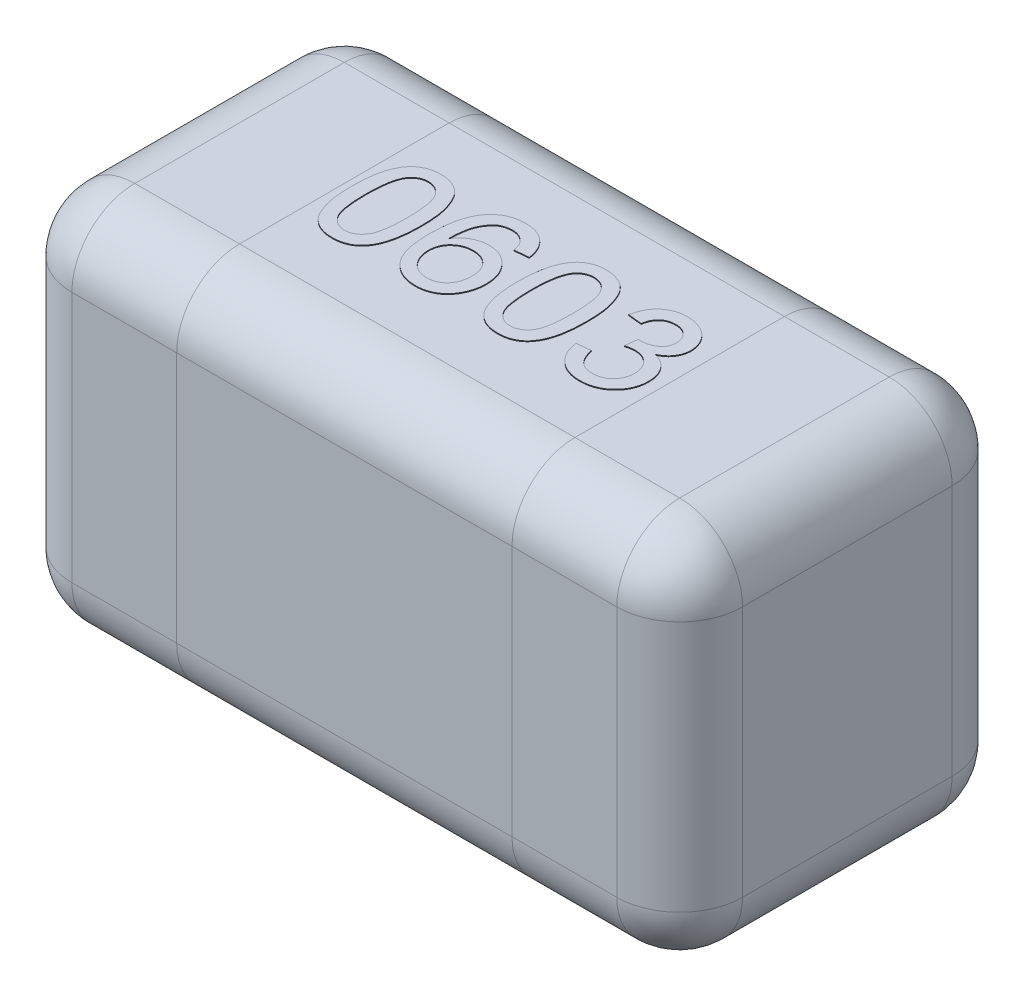
from build123d import *

# Parameters (mm, degrees)
SKETCH1_W      = 1.6
SKETCH1_H      = 0.8
EXTRUDE1_DEPTH = 0.9
FILLET1_R      = 0.15
EXTRUDE2_DEPTH = 0.002


with BuildPart() as part:
    # Sketch1 → Extrude1 (new body)
    with BuildSketch(Plane(origin=(0, 0, 0), x_dir=(1, 0, 0), z_dir=(0, 1, 0))):
        Rectangle(SKETCH1_W, SKETCH1_H)
    extrude(amount=EXTRUDE1_DEPTH)

    # Fillet1
    fillet1_edges = [part.edges().sort_by_distance(p)[0] for p in [
        (0.8, 0.9, 0),
        (0, 0.9, -0.4),
        (-0.8, 0.9, 0),
        (0, 0, -0.4),
        (0.8, 0, 0),
        (0, 0, 0.4),
        (-0.8, 0, 0),
        (0, 0.9, 0.4),
        (-0.8, 0.45, -0.4),
        (0.8, 0.45, -0.4),
        (0.8, 0.45, 0.4),
        (-0.8, 0.45, 0.4),
    ]]
    fillet(fillet1_edges, radius=FILLET1_R)

    # Sketch3 → Extrude2 (add)
    with BuildSketch(Plane(origin=(0, 0.9, 0), x_dir=(1, 0, 0), z_dir=(0, 1, 0))):
        with BuildLine():
            add(Edge.make_bspline(
                [(-0.383536419, 0.001666679), (-0.383503245, 0.005337042), (-0.38343827, 0.012525738), (-0.383035257, 0.023044091), (-0.382331628, 0.033032936), (-0.381281304, 0.042483597), (-0.380037523, 0.051417406), (-0.378420601, 0.059821615), (-0.376601328, 0.067715078), (-0.374418526, 0.07508957), (-0.372020342, 0.082008496), (-0.369299526, 0.088460757), (-0.366238239, 0.094439512), (-0.362986924, 0.100006765), (-0.359374425, 0.105075921), (-0.355618786, 0.109789243), (-0.351447068, 0.113973873), (-0.347032741, 0.117737484), (-0.342310804, 0.12105865), (-0.337306239, 0.123924417), (-0.332038302, 0.126454682), (-0.326406594, 0.128359465), (-0.320528026, 0.129912267), (-0.314357349, 0.131054526), (-0.307887763, 0.131727927), (-0.30346671, 0.13179683), (-0.301218512, 0.131831868)],
                knots=[0, 0, 0, 0, 1.1011e-05, 2.1566e-05, 3.1573e-05, 4.1044e-05, 5.0088e-05, 5.8625e-05, 6.6711e-05, 7.4379e-05, 8.1685e-05, 8.867e-05, 9.5366e-05, 0.000101825, 0.000107991, 0.000114026, 0.000119883, 0.000125687, 0.00013141, 0.000137173, 0.000142973, 0.000148912, 0.000154976, 0.000161203, 0.00016772, 0.000174462, 0.000174462, 0.000174462, 0.000174462], degree=3))
            add(Edge.make_bspline(
                [(-0.301218512, 0.131831868), (-0.297920113, 0.131734898), (-0.291440277, 0.131544395), (-0.281979682, 0.129990691), (-0.273063682, 0.127332839), (-0.264698068, 0.123747283), (-0.257025849, 0.119192937), (-0.250174234, 0.113656435), (-0.24421713, 0.10719591), (-0.239219547, 0.099734806), (-0.234851161, 0.091478951), (-0.230970383, 0.08239129), (-0.227462272, 0.072482005), (-0.22497284, 0.063611812), (-0.223197131, 0.055954747), (-0.222021752, 0.049639416), (-0.221045952, 0.042825138), (-0.220298357, 0.035528399), (-0.219684974, 0.027757383), (-0.219211285, 0.019507252), (-0.21897084, 0.010757385), (-0.218924456, 0.004753721), (-0.218900606, 0.001666679)],
                knots=[0, 0, 0, 0, 9.892e-06, 1.9432e-05, 2.8662e-05, 3.7742e-05, 4.6671e-05, 5.5341e-05, 6.408e-05, 7.2927e-05, 8.2203e-05, 9.2066e-05, 0.000102546, 0.000113719, 0.000119684, 0.000126122, 0.000132983, 0.00014033, 0.000148123, 0.000156368, 0.000165118, 0.000174379, 0.000174379, 0.000174379, 0.000174379], degree=3))
            add(Edge.make_bspline(
                [(-0.218900606, 0.001666679), (-0.218934401, -0.001986444), (-0.219000427, -0.009123539), (-0.219392642, -0.019557553), (-0.220138669, -0.029471036), (-0.22105667, -0.038886699), (-0.222445412, -0.047779404), (-0.223941857, -0.056186936), (-0.22579259, -0.064071116), (-0.227951961, -0.071435401), (-0.230383903, -0.078318728), (-0.233050903, -0.08477312), (-0.236004862, -0.090794165), (-0.239333701, -0.096323138), (-0.24288511, -0.101433426), (-0.2466851, -0.106144199), (-0.250814234, -0.110387655), (-0.255268341, -0.114139976), (-0.259957124, -0.117520039), (-0.264973856, -0.120414099), (-0.27029658, -0.122811778), (-0.27588973, -0.124861674), (-0.28181006, -0.126363718), (-0.28801088, -0.127513508), (-0.294515039, -0.128190589), (-0.298953192, -0.128258204), (-0.301218512, -0.128292716)],
                knots=[0, 0, 0, 0, 1.096e-05, 2.1412e-05, 3.1316e-05, 4.0782e-05, 4.9783e-05, 5.831e-05, 6.6396e-05, 7.4064e-05, 8.1321e-05, 8.8287e-05, 9.5005e-05, 0.00010142, 0.000107628, 0.000113663, 0.000119557, 0.00012536, 0.000131114, 0.000136876, 0.000142701, 0.000148609, 0.000154724, 0.000161, 0.000167517, 0.000174312, 0.000174312, 0.000174312, 0.000174312], degree=3))
            add(Edge.make_bspline(
                [(-0.301218512, -0.128292716), (-0.30418861, -0.128207994), (-0.309979483, -0.128042809), (-0.318436626, -0.126920479), (-0.326374106, -0.124945125), (-0.333858871, -0.122295898), (-0.34080679, -0.118752403), (-0.347251037, -0.11444105), (-0.353321103, -0.109462146), (-0.356815403, -0.105533906), (-0.358583803, -0.103545896)],
                knots=[0, 0, 0, 0, 8.91e-06, 1.7372e-05, 2.5533e-05, 3.341e-05, 4.1141e-05, 4.8861e-05, 5.664e-05, 6.4612e-05, 6.4612e-05, 6.4612e-05, 6.4612e-05], degree=3))
            add(Edge.make_bspline(
                [(-0.358583803, -0.103545896), (-0.360619273, -0.100609701), (-0.364816498, -0.094555141), (-0.369728987, -0.084231556), (-0.374111014, -0.072866738), (-0.377550101, -0.060237711), (-0.380243764, -0.046444988), (-0.382189261, -0.031461504), (-0.383290221, -0.015293733), (-0.3834525, -0.004114416), (-0.383536419, 0.001666679)],
                knots=[0, 0, 0, 0, 1.0702e-05, 2.2069e-05, 3.4184e-05, 4.7216e-05, 6.1271e-05, 7.6319e-05, 9.2514e-05, 0.000109857, 0.000109857, 0.000109857, 0.000109857], degree=3))
        make_face()
        with BuildLine():
            add(Edge.make_bspline(
                [(-0.350609256, 0.001769576), (-0.350576562, -0.003170235), (-0.350513978, -0.012626126), (-0.349860131, -0.026135497), (-0.34873456, -0.038322794), (-0.347246481, -0.049171143), (-0.345281615, -0.058695218), (-0.342814493, -0.066870748), (-0.34003346, -0.07379586), (-0.336591985, -0.07938472), (-0.332823949, -0.083940457), (-0.328933709, -0.087858537), (-0.324829742, -0.091188816), (-0.320538825, -0.09396559), (-0.315994382, -0.09606798), (-0.311246106, -0.097591797), (-0.306292962, -0.098468731), (-0.302919647, -0.09859473), (-0.301218512, -0.09865827)],
                knots=[0, 0, 0, 0, 1.4819e-05, 2.8366e-05, 4.0561e-05, 5.1526e-05, 6.1202e-05, 6.9698e-05, 7.7123e-05, 8.352e-05, 8.9297e-05, 9.4827e-05, 0.000100058, 0.000105124, 0.000110119, 0.000115033, 0.000120049, 0.000125152, 0.000125152, 0.000125152, 0.000125152], degree=3))
            add(Edge.make_bspline(
                [(-0.301218512, -0.09865827), (-0.299517804, -0.098593341), (-0.296145333, -0.098464589), (-0.291180745, -0.097606993), (-0.286450942, -0.096004731), (-0.281913275, -0.093909766), (-0.277591171, -0.091196284), (-0.273507359, -0.087853425), (-0.269596627, -0.083937671), (-0.265845517, -0.079328982), (-0.26243026, -0.073714283), (-0.259597059, -0.066794813), (-0.257168385, -0.058604965), (-0.255192738, -0.049085742), (-0.253698521, -0.038254546), (-0.252579755, -0.026101051), (-0.251921532, -0.012609061), (-0.251859981, -0.003170257), (-0.251827768, 0.001769576)],
                knots=[0, 0, 0, 0, 5.103e-06, 1.0119e-05, 1.5048e-05, 2.0043e-05, 2.5082e-05, 3.0313e-05, 3.5843e-05, 4.166e-05, 4.8101e-05, 5.5478e-05, 6.4023e-05, 7.37e-05, 8.4614e-05, 9.6809e-05, 0.000110305, 0.000125123, 0.000125123, 0.000125123, 0.000125123], degree=3))
            add(Edge.make_bspline(
                [(-0.251827768, 0.001769576), (-0.25185895, 0.006606627), (-0.251918692, 0.015874235), (-0.252593892, 0.029123348), (-0.25365199, 0.041106086), (-0.2550993, 0.051833497), (-0.257022775, 0.061293933), (-0.259355688, 0.069507536), (-0.262135702, 0.076456788), (-0.265441129, 0.082211494), (-0.269120731, 0.086931915), (-0.272964424, 0.09101785), (-0.277068301, 0.094492804), (-0.28150507, 0.097280464), (-0.286131725, 0.099529444), (-0.291054577, 0.101077249), (-0.296225236, 0.102028172), (-0.299773792, 0.102140361), (-0.301578653, 0.102197422)],
                knots=[0, 0, 0, 0, 1.451e-05, 2.7801e-05, 3.9785e-05, 5.059e-05, 6.0257e-05, 6.8723e-05, 7.6175e-05, 8.2653e-05, 8.8559e-05, 9.4091e-05, 9.946e-05, 0.000104641, 0.000109772, 0.000114849, 0.000120076, 0.000125487, 0.000125487, 0.000125487, 0.000125487], degree=3))
            add(Edge.make_bspline(
                [(-0.301578653, 0.102197422), (-0.303279681, 0.102152777), (-0.306633889, 0.102064742), (-0.311544889, 0.101224452), (-0.316198987, 0.099819298), (-0.320649502, 0.097915882), (-0.324785331, 0.095354259), (-0.328770489, 0.092363383), (-0.332418328, 0.088719333), (-0.334616483, 0.085995099), (-0.335740584, 0.08460197)],
                knots=[0, 0, 0, 0, 5.1e-06, 1.0056e-05, 1.4891e-05, 1.966e-05, 2.4531e-05, 2.9449e-05, 3.4579e-05, 3.9948e-05, 3.9948e-05, 3.9948e-05, 3.9948e-05], degree=3))
            add(Edge.make_bspline(
                [(-0.335740584, 0.08460197), (-0.336964387, 0.082555894), (-0.339548802, 0.078235014), (-0.342440611, 0.070725147), (-0.344995121, 0.062142798), (-0.34709833, 0.052355922), (-0.348619854, 0.041381307), (-0.349821038, 0.029231698), (-0.350445009, 0.015890133), (-0.350552996, 0.006606292), (-0.350609256, 0.001769576)],
                knots=[0, 0, 0, 0, 7.141e-06, 1.508e-05, 2.4049e-05, 3.3999e-05, 4.5073e-05, 5.7272e-05, 7.0614e-05, 8.5125e-05, 8.5125e-05, 8.5125e-05, 8.5125e-05], degree=3))
        make_face(mode=Mode.SUBTRACT)
        with BuildLine():
            Line((-0.024630346, 0.065977543), (-0.057557509, 0.062684827))
            add(Edge.make_bspline(
                [(-0.057557509, 0.062684827), (-0.05826805, 0.065516739), (-0.059605536, 0.070847376), (-0.06241023, 0.078077583), (-0.065500943, 0.084193107), (-0.068186101, 0.087486148), (-0.069442156, 0.089026557)],
                knots=[0, 0, 0, 0, 8.749e-06, 1.647e-05, 2.3237e-05, 2.9184e-05, 2.9184e-05, 2.9184e-05, 2.9184e-05], degree=3))
            add(Edge.make_bspline(
                [(-0.069442156, 0.089026557), (-0.070520334, 0.0900772), (-0.072640859, 0.092143573), (-0.076121989, 0.094837104), (-0.079791677, 0.097119199), (-0.083661013, 0.098968041), (-0.087709093, 0.100428521), (-0.091952687, 0.101450204), (-0.096382179, 0.102082684), (-0.099400325, 0.10215885), (-0.100928756, 0.102197422)],
                knots=[0, 0, 0, 0, 4.513e-06, 8.877e-06, 1.3174e-05, 1.7454e-05, 2.1718e-05, 2.6061e-05, 3.0528e-05, 3.5112e-05, 3.5112e-05, 3.5112e-05, 3.5112e-05], degree=3))
            add(Edge.make_bspline(
                [(-0.100928756, 0.102197422), (-0.103406605, 0.102117638), (-0.108302727, 0.101959989), (-0.115486212, 0.100416617), (-0.122463396, 0.098106714), (-0.126786019, 0.095765152), (-0.128968293, 0.094583016)],
                knots=[0, 0, 0, 0, 7.423e-06, 1.4668e-05, 2.1957e-05, 2.9388e-05, 2.9388e-05, 2.9388e-05, 2.9388e-05], degree=3))
            add(Edge.make_bspline(
                [(-0.128968293, 0.094583016), (-0.131114423, 0.092804891), (-0.135519915, 0.089154828), (-0.141269136, 0.082410274), (-0.146410589, 0.0745576), (-0.150202503, 0.06722653), (-0.152871131, 0.060653582), (-0.154597055, 0.055020365), (-0.156071643, 0.048796819), (-0.157300057, 0.041994671), (-0.158250156, 0.034608403), (-0.159044249, 0.026633324), (-0.15948345, 0.018049212), (-0.159581272, 0.012128344), (-0.159631713, 0.00907529)],
                knots=[0, 0, 0, 0, 8.349e-06, 1.7138e-05, 2.6456e-05, 3.6465e-05, 4.1844e-05, 4.7719e-05, 5.412e-05, 6.1023e-05, 6.8445e-05, 7.6456e-05, 8.5061e-05, 9.4221e-05, 9.4221e-05, 9.4221e-05, 9.4221e-05], degree=3))
            add(Edge.make_bspline(
                [(-0.159631713, 0.00907529), (-0.157690438, 0.011802723), (-0.153890275, 0.017141839), (-0.147186499, 0.024125799), (-0.139866285, 0.030029462), (-0.13192145, 0.034743141), (-0.123559298, 0.038396359), (-0.114964225, 0.041025178), (-0.106151296, 0.042638817), (-0.100215195, 0.042831467), (-0.09722445, 0.042928529)],
                knots=[0, 0, 0, 0, 1.0032e-05, 1.9639e-05, 2.8936e-05, 3.8165e-05, 4.7265e-05, 5.6249e-05, 6.5079e-05, 7.4046e-05, 7.4046e-05, 7.4046e-05, 7.4046e-05], degree=3))
            add(Edge.make_bspline(
                [(-0.09722445, 0.042928529), (-0.094648686, 0.042859228), (-0.089559774, 0.04272231), (-0.082065775, 0.041637295), (-0.074881238, 0.03973953), (-0.067943904, 0.037267256), (-0.061387084, 0.03389162), (-0.055050754, 0.029946495), (-0.049081666, 0.025145731), (-0.043404274, 0.019751525), (-0.038235229, 0.013754368), (-0.033660257, 0.007299719), (-0.02984777, 0.000372108), (-0.026756285, -0.006982072), (-0.024336657, -0.014736058), (-0.022578509, -0.022911872), (-0.021549314, -0.031525671), (-0.021409136, -0.037414409), (-0.02133763, -0.040418351)],
                knots=[0, 0, 0, 0, 7.726e-06, 1.5264e-05, 2.2651e-05, 2.9992e-05, 3.7308e-05, 4.4731e-05, 5.2348e-05, 6.0244e-05, 6.8196e-05, 7.6061e-05, 8.3937e-05, 9.1868e-05, 9.9955e-05, 0.00010827, 0.000116924, 0.000125934, 0.000125934, 0.000125934, 0.000125934], degree=3))
            add(Edge.make_bspline(
                [(-0.02133763, -0.040418351), (-0.021465744, -0.044388292), (-0.021718575, -0.052222876), (-0.02374794, -0.063760347), (-0.02701796, -0.074881354), (-0.030929731, -0.083688228), (-0.034523627, -0.090435234), (-0.037575266, -0.09515439), (-0.040838328, -0.099589207), (-0.044251006, -0.103800713), (-0.048060824, -0.107596153), (-0.052036809, -0.111154368), (-0.056310381, -0.114352339), (-0.060755852, -0.117296475), (-0.065457198, -0.11984934), (-0.070277623, -0.122117837), (-0.075256809, -0.124050179), (-0.080410832, -0.125567394), (-0.085713296, -0.126822617), (-0.091181851, -0.127685698), (-0.096802104, -0.128217982), (-0.100601712, -0.128267612), (-0.102523665, -0.128292716)],
                knots=[0, 0, 0, 0, 1.1903e-05, 2.3491e-05, 3.5032e-05, 4.6598e-05, 5.233e-05, 5.7953e-05, 6.3438e-05, 6.8846e-05, 7.4194e-05, 7.9552e-05, 8.4841e-05, 9.0192e-05, 9.5534e-05, 0.000100874, 0.000106167, 0.000111538, 0.00011698, 0.000122503, 0.000128134, 0.000133899, 0.000133899, 0.000133899, 0.000133899], degree=3))
            add(Edge.make_bspline(
                [(-0.102523665, -0.128292716), (-0.105769485, -0.128202708), (-0.112135109, -0.128026186), (-0.12145213, -0.126670063), (-0.13029905, -0.124403791), (-0.138694686, -0.121235286), (-0.146664615, -0.117235114), (-0.154130294, -0.112220622), (-0.161133034, -0.106340498), (-0.167678232, -0.09956064), (-0.173612757, -0.091731943), (-0.17868467, -0.082695225), (-0.18300639, -0.072529587), (-0.186543342, -0.061207062), (-0.189219793, -0.048715808), (-0.191146951, -0.035082653), (-0.192332132, -0.020305644), (-0.192481527, -0.010065927), (-0.192558875, -0.004764408)],
                knots=[0, 0, 0, 0, 9.735e-06, 1.9092e-05, 2.8176e-05, 3.7082e-05, 4.5963e-05, 5.4867e-05, 6.3998e-05, 7.3349e-05, 8.3083e-05, 9.3383e-05, 0.000104354, 0.000116167, 0.000128913, 0.000142635, 0.000157448, 0.000173351, 0.000173351, 0.000173351, 0.000173351], degree=3))
            add(Edge.make_bspline(
                [(-0.192558875, -0.004764408), (-0.19254605, -0.001745552), (-0.192520754, 0.004208665), (-0.192114269, 0.012971787), (-0.19164798, 0.021434699), (-0.190849068, 0.029563639), (-0.189905763, 0.037395168), (-0.18863986, 0.04488323), (-0.187280433, 0.052086028), (-0.185627646, 0.058946854), (-0.183785193, 0.065530248), (-0.181664466, 0.071763875), (-0.179424453, 0.077728385), (-0.176883204, 0.08332969), (-0.174174825, 0.088659016), (-0.171181109, 0.093617741), (-0.168041514, 0.098319248), (-0.165723734, 0.101218345), (-0.164570787, 0.10266046)],
                knots=[0, 0, 0, 0, 9.056e-06, 1.7861e-05, 2.6314e-05, 3.4479e-05, 4.236e-05, 4.9973e-05, 5.7258e-05, 6.4346e-05, 7.1137e-05, 7.7759e-05, 8.4094e-05, 9.0242e-05, 9.6202e-05, 0.000102016, 0.00010761, 0.000113147, 0.000113147, 0.000113147, 0.000113147], degree=3))
            add(Edge.make_bspline(
                [(-0.164570787, 0.10266046), (-0.162496656, 0.104993449), (-0.158408351, 0.109591987), (-0.151414546, 0.115532209), (-0.143962058, 0.120606072), (-0.135932029, 0.124705315), (-0.127385832, 0.127901215), (-0.118318109, 0.130221156), (-0.108703558, 0.131566562), (-0.102133474, 0.131742), (-0.098767911, 0.131831868)],
                knots=[0, 0, 0, 0, 9.355e-06, 1.844e-05, 2.7444e-05, 3.6349e-05, 4.5418e-05, 5.4764e-05, 6.4375e-05, 7.447e-05, 7.447e-05, 7.447e-05, 7.447e-05], degree=3))
            add(Edge.make_bspline(
                [(-0.098767911, 0.131831868), (-0.096261875, 0.13178757), (-0.091338567, 0.131700541), (-0.084124664, 0.13086549), (-0.077262974, 0.129469827), (-0.070738215, 0.127587235), (-0.064588327, 0.125081264), (-0.058742409, 0.122111417), (-0.053259821, 0.118538877), (-0.048180254, 0.114412455), (-0.043491127, 0.109849121), (-0.039291141, 0.104810557), (-0.035596121, 0.099359559), (-0.032377172, 0.09348479), (-0.029663059, 0.087214061), (-0.027434637, 0.08052042), (-0.025740887, 0.073405587), (-0.025005658, 0.068487879), (-0.024630346, 0.065977543)],
                knots=[0, 0, 0, 0, 7.516e-06, 1.4766e-05, 2.1748e-05, 2.8504e-05, 3.5106e-05, 4.1641e-05, 4.8148e-05, 5.4696e-05, 6.1245e-05, 6.7747e-05, 7.4339e-05, 8.0971e-05, 8.7814e-05, 9.481e-05, 0.00010211, 0.000109723, 0.000109723, 0.000109723, 0.000109723], degree=3))
        make_face()
        with BuildLine():
            add(Edge.make_bspline(
                [(-0.159631713, -0.039749518), (-0.159540127, -0.0423277), (-0.159358158, -0.047450217), (-0.157966304, -0.055053715), (-0.155693308, -0.062472313), (-0.152578141, -0.069623622), (-0.148731484, -0.076267913), (-0.144162551, -0.082155213), (-0.138970517, -0.087199082), (-0.133183284, -0.091410466), (-0.126814437, -0.094646798), (-0.119978043, -0.096990744), (-0.112665934, -0.098407433), (-0.107623451, -0.098573395), (-0.105044651, -0.09865827)],
                knots=[0, 0, 0, 0, 7.731e-06, 1.5361e-05, 2.3108e-05, 3.0964e-05, 3.8712e-05, 4.6081e-05, 5.3248e-05, 6.0359e-05, 6.7469e-05, 7.4596e-05, 8.1982e-05, 8.9713e-05, 8.9713e-05, 8.9713e-05, 8.9713e-05], degree=3))
            add(Edge.make_bspline(
                [(-0.105044651, -0.09865827), (-0.103206963, -0.09860857), (-0.099619959, -0.098511559), (-0.094368002, -0.097759826), (-0.089357055, -0.096603884), (-0.084616133, -0.094895987), (-0.080151668, -0.092716241), (-0.075940482, -0.090063347), (-0.071985296, -0.086929362), (-0.068333932, -0.08332004), (-0.065033889, -0.079305825), (-0.06216659, -0.07491135), (-0.059634496, -0.070208916), (-0.057729958, -0.065082963), (-0.056178035, -0.059664812), (-0.055037075, -0.053903233), (-0.054367211, -0.047791611), (-0.054299426, -0.043592713), (-0.054264792, -0.041447325)],
                knots=[0, 0, 0, 0, 5.511e-06, 1.0757e-05, 1.5886e-05, 2.0914e-05, 2.5839e-05, 3.0763e-05, 3.5817e-05, 4.0947e-05, 4.6138e-05, 5.1375e-05, 5.6668e-05, 6.2124e-05, 6.7742e-05, 7.3564e-05, 7.9723e-05, 8.6157e-05, 8.6157e-05, 8.6157e-05, 8.6157e-05], degree=3))
            add(Edge.make_bspline(
                [(-0.054264792, -0.041447325), (-0.054296915, -0.03938714), (-0.054359735, -0.035358188), (-0.055066588, -0.029479091), (-0.056096303, -0.02392126), (-0.057677035, -0.01873146), (-0.059617113, -0.013854749), (-0.062048009, -0.009327606), (-0.064880463, -0.005111555), (-0.068201399, -0.001318233), (-0.071833079, 0.002137705), (-0.075821626, 0.005139518), (-0.080119171, 0.007674711), (-0.084741216, 0.009750195), (-0.08969647, 0.011340808), (-0.094974671, 0.012443142), (-0.10054612, 0.01321262), (-0.104373061, 0.013266512), (-0.106330868, 0.013294083)],
                knots=[0, 0, 0, 0, 6.177e-06, 1.208e-05, 1.7741e-05, 2.3112e-05, 2.8329e-05, 3.3462e-05, 3.8499e-05, 4.3532e-05, 4.8555e-05, 5.3515e-05, 5.8473e-05, 6.3494e-05, 6.8684e-05, 7.4052e-05, 7.9655e-05, 8.5524e-05, 8.5524e-05, 8.5524e-05, 8.5524e-05], degree=3))
            add(Edge.make_bspline(
                [(-0.106330868, 0.013294083), (-0.108151632, 0.013265635), (-0.11173962, 0.013209575), (-0.117001435, 0.012434094), (-0.122072756, 0.011329551), (-0.126933335, 0.009722596), (-0.131584845, 0.007653144), (-0.136026254, 0.005135901), (-0.140218993, 0.002098757), (-0.144201292, -0.001302496), (-0.147835092, -0.005080818), (-0.151023219, -0.009168514), (-0.15362359, -0.013591881), (-0.155896735, -0.018242706), (-0.15756219, -0.023230622), (-0.158747182, -0.028488757), (-0.159481847, -0.034018081), (-0.15958098, -0.037809315), (-0.159631713, -0.039749518)],
                knots=[0, 0, 0, 0, 5.457e-06, 1.0754e-05, 1.5922e-05, 2.1014e-05, 2.6081e-05, 3.1174e-05, 3.6299e-05, 4.1589e-05, 4.6866e-05, 5.2001e-05, 5.7101e-05, 6.2232e-05, 6.7504e-05, 7.2833e-05, 7.8385e-05, 8.4205e-05, 8.4205e-05, 8.4205e-05, 8.4205e-05], degree=3))
        make_face(mode=Mode.SUBTRACT)
        with BuildLine():
            add(Edge.make_bspline(
                [(0.011589533, 0.001666679), (0.011622707, 0.005337042), (0.011687681, 0.012525738), (0.012090695, 0.023044091), (0.012794323, 0.033032936), (0.013844648, 0.042483597), (0.015088428, 0.051417406), (0.016705351, 0.059821615), (0.018524624, 0.067715078), (0.020707425, 0.07508957), (0.023105609, 0.082008496), (0.025826425, 0.088460757), (0.028887712, 0.094439512), (0.032139028, 0.100006765), (0.035751527, 0.105075921), (0.039507166, 0.109789243), (0.043678883, 0.113973873), (0.04809321, 0.117737484), (0.052815148, 0.12105865), (0.057819713, 0.123924417), (0.063087649, 0.126454682), (0.068719358, 0.128359465), (0.074597926, 0.129912267), (0.080768603, 0.131054526), (0.087238189, 0.131727927), (0.091659242, 0.13179683), (0.093907439, 0.131831868)],
                knots=[0, 0, 0, 0, 1.1011e-05, 2.1566e-05, 3.1573e-05, 4.1044e-05, 5.0088e-05, 5.8625e-05, 6.6711e-05, 7.4379e-05, 8.1685e-05, 8.867e-05, 9.5366e-05, 0.000101825, 0.000107991, 0.000114026, 0.000119883, 0.000125687, 0.00013141, 0.000137173, 0.000142973, 0.000148912, 0.000154976, 0.000161203, 0.00016772, 0.000174462, 0.000174462, 0.000174462, 0.000174462], degree=3))
            add(Edge.make_bspline(
                [(0.093907439, 0.131831868), (0.097205838, 0.131734898), (0.103685674, 0.131544395), (0.113146269, 0.129990691), (0.12206227, 0.127332839), (0.130427884, 0.123747283), (0.138100103, 0.119192937), (0.144951717, 0.113656435), (0.150908822, 0.10719591), (0.155906405, 0.099734806), (0.16027479, 0.091478951), (0.164155569, 0.08239129), (0.167663679, 0.072482005), (0.170153111, 0.063611812), (0.171928821, 0.055954747), (0.1731042, 0.049639416), (0.17408, 0.042825138), (0.174827594, 0.035528399), (0.175440978, 0.027757383), (0.175914666, 0.019507252), (0.176155111, 0.010757385), (0.176201496, 0.004753721), (0.176225346, 0.001666679)],
                knots=[0, 0, 0, 0, 9.892e-06, 1.9432e-05, 2.8662e-05, 3.7742e-05, 4.6671e-05, 5.5341e-05, 6.408e-05, 7.2927e-05, 8.2203e-05, 9.2066e-05, 0.000102546, 0.000113719, 0.000119684, 0.000126122, 0.000132983, 0.00014033, 0.000148123, 0.000156368, 0.000165118, 0.000174379, 0.000174379, 0.000174379, 0.000174379], degree=3))
            add(Edge.make_bspline(
                [(0.176225346, 0.001666679), (0.17619155, -0.001986444), (0.176125524, -0.009123539), (0.17573331, -0.019557553), (0.174987282, -0.029471036), (0.174069282, -0.038886699), (0.17268054, -0.047779404), (0.171184094, -0.056186936), (0.169333362, -0.064071116), (0.167173991, -0.071435401), (0.164742049, -0.078318728), (0.162075048, -0.08477312), (0.159121089, -0.090794165), (0.15579225, -0.096323138), (0.152240841, -0.101433426), (0.148440852, -0.106144199), (0.144311718, -0.110387655), (0.139857611, -0.114139976), (0.135168827, -0.117520039), (0.130152095, -0.120414099), (0.124829372, -0.122811778), (0.119236221, -0.124861674), (0.113315892, -0.126363718), (0.107115072, -0.127513508), (0.100610913, -0.128190589), (0.09617276, -0.128258204), (0.093907439, -0.128292716)],
                knots=[0, 0, 0, 0, 1.096e-05, 2.1412e-05, 3.1316e-05, 4.0782e-05, 4.9783e-05, 5.831e-05, 6.6396e-05, 7.4064e-05, 8.1321e-05, 8.8287e-05, 9.5005e-05, 0.00010142, 0.000107628, 0.000113663, 0.000119557, 0.00012536, 0.000131114, 0.000136876, 0.000142701, 0.000148609, 0.000154724, 0.000161, 0.000167517, 0.000174312, 0.000174312, 0.000174312, 0.000174312], degree=3))
            add(Edge.make_bspline(
                [(0.093907439, -0.128292716), (0.090937342, -0.128207994), (0.085146469, -0.128042809), (0.076689325, -0.126920479), (0.068751845, -0.124945125), (0.06126708, -0.122295898), (0.054319162, -0.118752403), (0.047874915, -0.11444105), (0.041804848, -0.109462146), (0.038310549, -0.105533906), (0.036542148, -0.103545896)],
                knots=[0, 0, 0, 0, 8.91e-06, 1.7372e-05, 2.5533e-05, 3.341e-05, 4.1141e-05, 4.8861e-05, 5.664e-05, 6.4612e-05, 6.4612e-05, 6.4612e-05, 6.4612e-05], degree=3))
            add(Edge.make_bspline(
                [(0.036542148, -0.103545896), (0.034506679, -0.100609701), (0.030309453, -0.094555141), (0.025396965, -0.084231556), (0.021014938, -0.072866738), (0.01757585, -0.060237711), (0.014882188, -0.046444988), (0.01293669, -0.031461504), (0.011835731, -0.015293733), (0.011673451, -0.004114416), (0.011589533, 0.001666679)],
                knots=[0, 0, 0, 0, 1.0702e-05, 2.2069e-05, 3.4184e-05, 4.7216e-05, 6.1271e-05, 7.6319e-05, 9.2514e-05, 0.000109857, 0.000109857, 0.000109857, 0.000109857], degree=3))
        make_face()
        with BuildLine():
            add(Edge.make_bspline(
                [(0.044516695, 0.001769576), (0.04454939, -0.003170235), (0.044611973, -0.012626126), (0.04526582, -0.026135497), (0.046391392, -0.038322794), (0.04787947, -0.049171143), (0.049844336, -0.058695218), (0.052311458, -0.066870748), (0.055092491, -0.07379586), (0.058533967, -0.07938472), (0.062302003, -0.083940457), (0.066192242, -0.087858537), (0.070296209, -0.091188816), (0.074587126, -0.09396559), (0.079131569, -0.09606798), (0.083879846, -0.097591797), (0.088832989, -0.098468731), (0.092206305, -0.09859473), (0.093907439, -0.09865827)],
                knots=[0, 0, 0, 0, 1.4819e-05, 2.8366e-05, 4.0561e-05, 5.1526e-05, 6.1202e-05, 6.9698e-05, 7.7123e-05, 8.352e-05, 8.9297e-05, 9.4827e-05, 0.000100058, 0.000105124, 0.000110119, 0.000115033, 0.000120049, 0.000125152, 0.000125152, 0.000125152, 0.000125152], degree=3))
            add(Edge.make_bspline(
                [(0.093907439, -0.09865827), (0.095608148, -0.098593341), (0.098980619, -0.098464589), (0.103945207, -0.097606993), (0.108675009, -0.096004731), (0.113212676, -0.093909766), (0.117534781, -0.091196284), (0.121618592, -0.087853425), (0.125529325, -0.083937671), (0.129280435, -0.079328982), (0.132695691, -0.073714283), (0.135528893, -0.066794813), (0.137957566, -0.058604965), (0.139933214, -0.049085742), (0.141427431, -0.038254546), (0.142546197, -0.026101051), (0.14320442, -0.012609061), (0.14326597, -0.003170257), (0.143298183, 0.001769576)],
                knots=[0, 0, 0, 0, 5.103e-06, 1.0119e-05, 1.5048e-05, 2.0043e-05, 2.5082e-05, 3.0313e-05, 3.5843e-05, 4.166e-05, 4.8101e-05, 5.5478e-05, 6.4023e-05, 7.37e-05, 8.4614e-05, 9.6809e-05, 0.000110305, 0.000125123, 0.000125123, 0.000125123, 0.000125123], degree=3))
            add(Edge.make_bspline(
                [(0.143298183, 0.001769576), (0.143267002, 0.006606627), (0.143207259, 0.015874235), (0.14253206, 0.029123348), (0.141473962, 0.041106086), (0.140026652, 0.051833497), (0.138103177, 0.061293933), (0.135770264, 0.069507536), (0.132990249, 0.076456788), (0.129684822, 0.082211494), (0.12600522, 0.086931915), (0.122161527, 0.09101785), (0.118057651, 0.094492804), (0.113620882, 0.097280464), (0.108994226, 0.099529444), (0.104071375, 0.101077249), (0.098900716, 0.102028172), (0.09535216, 0.102140361), (0.093547299, 0.102197422)],
                knots=[0, 0, 0, 0, 1.451e-05, 2.7801e-05, 3.9785e-05, 5.059e-05, 6.0257e-05, 6.8723e-05, 7.6175e-05, 8.2653e-05, 8.8559e-05, 9.4091e-05, 9.946e-05, 0.000104641, 0.000109772, 0.000114849, 0.000120076, 0.000125487, 0.000125487, 0.000125487, 0.000125487], degree=3))
            add(Edge.make_bspline(
                [(0.093547299, 0.102197422), (0.091846271, 0.102152777), (0.088492063, 0.102064742), (0.083581062, 0.101224452), (0.078926965, 0.099819298), (0.074476449, 0.097915882), (0.070340621, 0.095354259), (0.066355463, 0.092363383), (0.062707624, 0.088719333), (0.060509468, 0.085995099), (0.059385367, 0.08460197)],
                knots=[0, 0, 0, 0, 5.1e-06, 1.0056e-05, 1.4891e-05, 1.966e-05, 2.4531e-05, 2.9449e-05, 3.4579e-05, 3.9948e-05, 3.9948e-05, 3.9948e-05, 3.9948e-05], degree=3))
            add(Edge.make_bspline(
                [(0.059385367, 0.08460197), (0.058161564, 0.082555894), (0.05557715, 0.078235014), (0.052685341, 0.070725147), (0.05013083, 0.062142798), (0.048027622, 0.052355922), (0.046506098, 0.041381307), (0.045304913, 0.029231698), (0.044680943, 0.015890133), (0.044572955, 0.006606292), (0.044516695, 0.001769576)],
                knots=[0, 0, 0, 0, 7.141e-06, 1.508e-05, 2.4049e-05, 3.3999e-05, 4.5073e-05, 5.7272e-05, 7.0614e-05, 8.5125e-05, 8.5125e-05, 8.5125e-05, 8.5125e-05], degree=3))
        make_face(mode=Mode.SUBTRACT)
        with BuildLine():
            Line((0.209152509, -0.055852958), (0.242079671, -0.052560242))
            add(Edge.make_bspline(
                [(0.242079671, -0.052560242), (0.24251863, -0.054538701), (0.243367982, -0.058366872), (0.245002239, -0.063851126), (0.246728374, -0.068941739), (0.248868253, -0.073524847), (0.25095631, -0.077787881), (0.253410092, -0.081554696), (0.256032007, -0.084923573), (0.258870524, -0.087882003), (0.261958352, -0.090429572), (0.265254323, -0.092658833), (0.268828144, -0.094520566), (0.272652454, -0.095994604), (0.276695042, -0.097187851), (0.280977877, -0.098064031), (0.285523607, -0.098585982), (0.288639336, -0.098633781), (0.290235647, -0.09865827)],
                knots=[0, 0, 0, 0, 6.077e-06, 1.1759e-05, 1.7162e-05, 2.2182e-05, 2.6922e-05, 3.1389e-05, 3.5639e-05, 3.9715e-05, 4.366e-05, 4.7627e-05, 5.1631e-05, 5.5721e-05, 5.9904e-05, 6.4263e-05, 6.882e-05, 7.3607e-05, 7.3607e-05, 7.3607e-05, 7.3607e-05], degree=3))
            add(Edge.make_bspline(
                [(0.290235647, -0.09865827), (0.292108062, -0.098631574), (0.295764893, -0.098579436), (0.301093499, -0.097797174), (0.306164607, -0.096723053), (0.310905866, -0.09503877), (0.315383295, -0.092980265), (0.319571387, -0.09043639), (0.323498808, -0.087449243), (0.327088093, -0.083998507), (0.330297982, -0.080202587), (0.333156839, -0.076193127), (0.33552073, -0.071935914), (0.337513134, -0.067490915), (0.338983789, -0.062786298), (0.340060427, -0.057880729), (0.340764015, -0.052752022), (0.340828333, -0.049252733), (0.340861159, -0.047466822)],
                knots=[0, 0, 0, 0, 5.612e-06, 1.096e-05, 1.6127e-05, 2.1139e-05, 2.6018e-05, 3.0889e-05, 3.5807e-05, 4.0793e-05, 4.5793e-05, 5.0703e-05, 5.554e-05, 6.0378e-05, 6.5291e-05, 7.0297e-05, 7.5434e-05, 8.0789e-05, 8.0789e-05, 8.0789e-05, 8.0789e-05], degree=3))
            add(Edge.make_bspline(
                [(0.340861159, -0.047466822), (0.340822579, -0.045767255), (0.340747101, -0.042442187), (0.340126607, -0.037561701), (0.339043858, -0.032928803), (0.33754291, -0.028516681), (0.335625007, -0.024331813), (0.333319743, -0.020339594), (0.330500216, -0.016627512), (0.327326591, -0.013155698), (0.323865091, -0.009957161), (0.320077011, -0.007236394), (0.316090528, -0.004888283), (0.31185813, -0.002992275), (0.307397393, -0.001487403), (0.302712567, -0.000405822), (0.297781129, 0.000214942), (0.294421896, 0.000290433), (0.292705184, 0.000329013)],
                knots=[0, 0, 0, 0, 5.098e-06, 9.973e-06, 1.4728e-05, 1.9348e-05, 2.393e-05, 2.8518e-05, 3.3149e-05, 3.7883e-05, 4.2618e-05, 4.7259e-05, 5.1847e-05, 5.6476e-05, 6.1145e-05, 6.595e-05, 7.0876e-05, 7.6025e-05, 7.6025e-05, 7.6025e-05, 7.6025e-05], degree=3))
            add(Edge.make_bspline(
                [(0.292705184, 0.000329013), (0.291193723, 0.000288969), (0.287986052, 0.000203988), (0.282923273, -0.000546365), (0.277315387, -0.001597035), (0.273440178, -0.002628112), (0.271405425, -0.003169498)],
                knots=[0, 0, 0, 0, 4.532e-06, 9.618e-06, 1.5329e-05, 2.1643e-05, 2.1643e-05, 2.1643e-05, 2.1643e-05], degree=3))
            Line((0.271405425, -0.003169498), (0.274801039, 0.026464948))
            add(Edge.make_bspline(
                [(0.274801039, 0.026464948), (0.275691969, 0.026367594), (0.277265935, 0.026195602), (0.278847838, 0.026132285), (0.279534319, 0.026104807)],
                knots=[0, 0, 0, 0, 2.688e-06, 4.748e-06, 4.748e-06, 4.748e-06, 4.748e-06], degree=3))
            add(Edge.make_bspline(
                [(0.279534319, 0.026104807), (0.282562527, 0.026220423), (0.288502921, 0.026447225), (0.297162863, 0.028331759), (0.305369948, 0.031298897), (0.311710451, 0.034839123), (0.316412354, 0.038168898), (0.31937728, 0.041171163), (0.322050313, 0.044357172), (0.324044614, 0.04801164), (0.325767568, 0.0518946), (0.326834502, 0.056159013), (0.327612599, 0.060701222), (0.327663931, 0.063847279), (0.327690294, 0.065463056)],
                knots=[0, 0, 0, 0, 9.076e-06, 1.7804e-05, 2.6464e-05, 3.5169e-05, 3.9511e-05, 4.3695e-05, 4.7793e-05, 5.1941e-05, 5.6136e-05, 6.0504e-05, 6.5088e-05, 6.9929e-05, 6.9929e-05, 6.9929e-05, 6.9929e-05], degree=3))
            add(Edge.make_bspline(
                [(0.327690294, 0.065463056), (0.327665963, 0.066768174), (0.327618377, 0.069320616), (0.327088252, 0.073062765), (0.32621149, 0.076608566), (0.325026459, 0.07999588), (0.323473359, 0.083206953), (0.321547393, 0.086237854), (0.319346911, 0.089150068), (0.316749319, 0.09179311), (0.313967525, 0.094274535), (0.310900086, 0.096364403), (0.30769299, 0.098220944), (0.30423313, 0.099623845), (0.300605921, 0.100777258), (0.296780359, 0.101585524), (0.292755046, 0.102128328), (0.289997417, 0.102174067), (0.288589288, 0.102197422)],
                knots=[0, 0, 0, 0, 3.913e-06, 7.653e-06, 1.1309e-05, 1.4856e-05, 1.84e-05, 2.1983e-05, 2.5616e-05, 2.9327e-05, 3.3083e-05, 3.6779e-05, 4.0442e-05, 4.4178e-05, 4.7953e-05, 5.1848e-05, 5.5894e-05, 6.0116e-05, 6.0116e-05, 6.0116e-05, 6.0116e-05], degree=3))
            add(Edge.make_bspline(
                [(0.288589288, 0.102197422), (0.285833616, 0.102089974), (0.280512004, 0.101882475), (0.272892967, 0.099962685), (0.265988745, 0.096856213), (0.260877192, 0.093213189), (0.257247539, 0.089730252), (0.254768295, 0.086778061), (0.252550751, 0.083517982), (0.250588622, 0.079951176), (0.248908419, 0.076063299), (0.247393763, 0.071902515), (0.246221278, 0.067402211), (0.245660148, 0.064283945), (0.245372387, 0.062684827)],
                knots=[0, 0, 0, 0, 8.255e-06, 1.5941e-05, 2.3401e-05, 3.0853e-05, 3.4638e-05, 3.8471e-05, 4.2396e-05, 4.6448e-05, 5.0664e-05, 5.5091e-05, 5.972e-05, 6.4594e-05, 6.4594e-05, 6.4594e-05, 6.4594e-05], degree=3))
            Line((0.245372387, 0.062684827), (0.212445225, 0.065977543))
            add(Edge.make_bspline(
                [(0.212445225, 0.065977543), (0.212960304, 0.068523507), (0.213970672, 0.073517616), (0.216029121, 0.08073047), (0.218539375, 0.087501286), (0.221553355, 0.093799021), (0.224928674, 0.099699045), (0.228822348, 0.105131372), (0.233143092, 0.110128301), (0.237898579, 0.114674589), (0.243024252, 0.118734932), (0.248494293, 0.122237511), (0.254263812, 0.125206451), (0.260338211, 0.127599943), (0.266712681, 0.129546214), (0.273405355, 0.130835623), (0.280385942, 0.131707844), (0.285139437, 0.131790018), (0.287560315, 0.131831868)],
                knots=[0, 0, 0, 0, 7.79e-06, 1.5281e-05, 2.2477e-05, 2.9427e-05, 3.6204e-05, 4.2843e-05, 4.9445e-05, 5.5995e-05, 6.2551e-05, 6.9031e-05, 7.545e-05, 8.1985e-05, 8.8593e-05, 9.5414e-05, 0.000102408, 0.000109667, 0.000109667, 0.000109667, 0.000109667], degree=3))
            add(Edge.make_bspline(
                [(0.287560315, 0.131831868), (0.290911385, 0.131723202), (0.297500674, 0.131509527), (0.307178803, 0.129812499), (0.316435883, 0.127027642), (0.325197422, 0.123167334), (0.333312682, 0.11845014), (0.340494019, 0.112796869), (0.346645427, 0.106305323), (0.351647429, 0.099046473), (0.355608313, 0.091317967), (0.358539248, 0.083295442), (0.360290526, 0.074988134), (0.360508258, 0.069364089), (0.360617457, 0.066543479)],
                knots=[0, 0, 0, 0, 1.0048e-05, 1.9758e-05, 2.9378e-05, 3.8984e-05, 4.8417e-05, 5.7465e-05, 6.6308e-05, 7.5143e-05, 8.3818e-05, 9.2297e-05, 0.000100702, 0.000109158, 0.000109158, 0.000109158, 0.000109158], degree=3))
            add(Edge.make_bspline(
                [(0.360617457, 0.066543479), (0.360506751, 0.063877165), (0.360288168, 0.058612656), (0.358605339, 0.050915012), (0.355761691, 0.04362236), (0.351918147, 0.036709113), (0.346934014, 0.030324775), (0.340822982, 0.024635749), (0.33368281, 0.019587598), (0.328331856, 0.016960091), (0.325580898, 0.015609274)],
                knots=[0, 0, 0, 0, 7.995e-06, 1.5785e-05, 2.3505e-05, 3.1406e-05, 3.9433e-05, 4.7695e-05, 5.6374e-05, 6.5556e-05, 6.5556e-05, 6.5556e-05, 6.5556e-05], degree=3))
            add(Edge.make_bspline(
                [(0.325580898, 0.015609274), (0.327425231, 0.015143616), (0.331037743, 0.014231529), (0.336226129, 0.012341709), (0.341103794, 0.010129205), (0.345735657, 0.007623284), (0.349987246, 0.004659627), (0.35400511, 0.001419203), (0.357637364, -0.002254048), (0.360989241, -0.006229204), (0.364039038, -0.010464666), (0.366605472, -0.015042822), (0.36882023, -0.019843321), (0.370708765, -0.024900981), (0.372065862, -0.030254799), (0.373036229, -0.035863301), (0.373676592, -0.041707), (0.373750713, -0.045698719), (0.373788322, -0.047724065)],
                knots=[0, 0, 0, 0, 5.704e-06, 1.1172e-05, 1.6537e-05, 2.1764e-05, 2.6944e-05, 3.2063e-05, 3.7228e-05, 4.2413e-05, 4.7652e-05, 5.2859e-05, 5.8131e-05, 6.3502e-05, 6.903e-05, 7.4672e-05, 8.0569e-05, 8.6644e-05, 8.6644e-05, 8.6644e-05, 8.6644e-05], degree=3))
            add(Edge.make_bspline(
                [(0.373788322, -0.047724065), (0.373725653, -0.050489151), (0.373602488, -0.055923431), (0.372434883, -0.063906512), (0.370526753, -0.071555377), (0.367886158, -0.078896), (0.364540107, -0.085958339), (0.360341363, -0.092642733), (0.35541437, -0.099003517), (0.349836154, -0.104979788), (0.343724684, -0.110472165), (0.337087861, -0.115228039), (0.330056994, -0.119266801), (0.322620643, -0.122560393), (0.31479852, -0.125148016), (0.306582844, -0.127002908), (0.297948191, -0.128093046), (0.292056638, -0.128225284), (0.289052327, -0.128292716)],
                knots=[0, 0, 0, 0, 8.291e-06, 1.6295e-05, 2.4143e-05, 3.1906e-05, 3.9661e-05, 4.7541e-05, 5.5537e-05, 6.3764e-05, 7.2036e-05, 8.0146e-05, 8.8212e-05, 9.632e-05, 0.000104503, 0.000112891, 0.00012155, 0.000130561, 0.000130561, 0.000130561, 0.000130561], degree=3))
            add(Edge.make_bspline(
                [(0.289052327, -0.128292716), (0.286356206, -0.128241932), (0.281048461, -0.128141956), (0.273279018, -0.127100373), (0.265835488, -0.125622246), (0.25877673, -0.123343537), (0.252020751, -0.120564688), (0.245681971, -0.117009569), (0.239646415, -0.112928431), (0.234027393, -0.108204674), (0.22885611, -0.102990881), (0.224242708, -0.097364169), (0.220281148, -0.091337029), (0.216788256, -0.084999641), (0.213965096, -0.078232541), (0.211766819, -0.071093829), (0.210090603, -0.063609999), (0.209468609, -0.058466772), (0.209152509, -0.055852958)],
                knots=[0, 0, 0, 0, 8.083e-06, 1.5913e-05, 2.3481e-05, 3.0819e-05, 3.8129e-05, 4.536e-05, 5.2581e-05, 5.9958e-05, 6.7344e-05, 7.4583e-05, 8.1747e-05, 8.8953e-05, 9.6263e-05, 0.000103699, 0.000111339, 0.000119233, 0.000119233, 0.000119233, 0.000119233], degree=3))
        make_face()
    extrude(amount=EXTRUDE2_DEPTH)


solid = part.part
